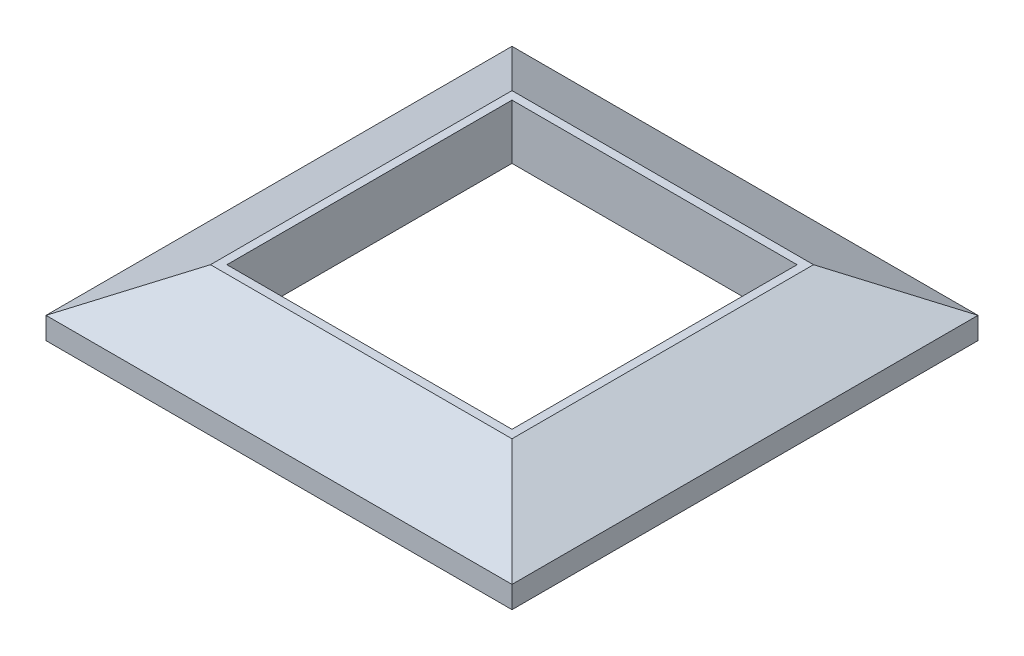
from build123d import *

# Parameters (mm, degrees)
EXTRUDE_1_DEPTH     = 42.5
SKETCH_2_OUTSIDE_W  = 111.162
SKETCH_2_OUTSIDE_H  = 38.162
CUT_EXTRUDE_1_DEPTH = 86
SKETCH_3_W          = 52
SKETCH_3_H          = 52
CUT_EXTRUDE_2_DEPTH = 13
SKETCH_4_W          = 82
SKETCH_4_H          = 82
CUT_EXTRUDE_3_DEPTH = 2


with BuildPart() as part:
    # Эскиз1 → Бобышка-Вытянуть1 (new body, symmetric)
    with BuildSketch(Plane.XY):
        Polygon((0, 0), (-85, 0), (-85, 4), (-70, 12), (-15, 12), (0, 4), align=None)
    extrude(amount=EXTRUDE_1_DEPTH, both=True)

    # Эскиз2 outside → Вырез-Вытянуть1 (cut, through all)
    with BuildSketch(Plane(origin=(0, 0, 0), x_dir=(0, 0, -1), z_dir=(1, 0, 0))):
        with Locations((0, 6)):
            Rectangle(SKETCH_2_OUTSIDE_W, SKETCH_2_OUTSIDE_H)
        Polygon((-42.5, 4), (-42.5, 0), (42.5, 0), (42.5, 4), (27.5, 12), (-27.5, 12), align=None, mode=Mode.SUBTRACT)
    extrude(amount=-CUT_EXTRUDE_1_DEPTH, mode=Mode.SUBTRACT)

    # Эскиз3 → Вырез-Вытянуть2 (cut, through all)
    with BuildSketch(Plane.XZ):
        with Locations((-42.5, 0)):
            Rectangle(SKETCH_3_W, SKETCH_3_H)
    extrude(amount=-CUT_EXTRUDE_2_DEPTH, mode=Mode.SUBTRACT)

    # Эскиз4 → Вырез-Вытянуть3 (cut)
    with BuildSketch(Plane.XZ):
        with Locations((-42.5, 0)):
            Rectangle(SKETCH_4_W, SKETCH_4_H)
    extrude(amount=-CUT_EXTRUDE_3_DEPTH, mode=Mode.SUBTRACT)


solid = part.part
